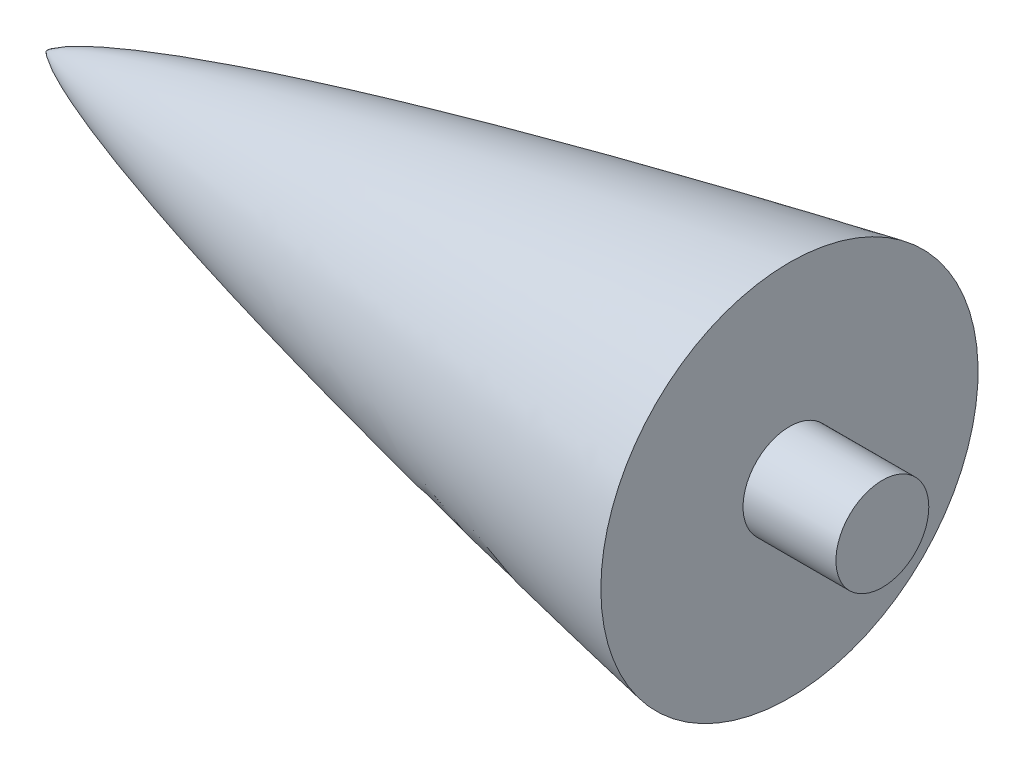
from build123d import *

# Parameters (mm, degrees)
SKETCH4_R           = 6.35
BOSS_EXTRUDE1_DEPTH = 12.7


with BuildPart() as part:
    # Sketch3 → Revolve1 (revolve)
    with BuildSketch(Plane.XY):
        with BuildLine():
            add(Edge.make_bspline(
                [(0, 0), (0.00238036, 0.007601136), (0.007984668, 0.02238567), (0.022840115, 0.050183387), (0.060232661, 0.101267557), (0.117712206, 0.166235145), (0.197260922, 0.242935889), (0.316636954, 0.345966559), (0.466313208, 0.461855796), (0.641104575, 0.585434487), (0.840927564, 0.716336462), (1.086304001, 0.86807874), (1.380514078, 1.039152539), (1.73039943, 1.230599419), (2.103920597, 1.423549594), (2.449515618, 1.594641657), (2.834258254, 1.779027289), (3.32523533, 2.006394535), (3.958237366, 2.287012777), (5.248383466, 2.831975888), (7.70022289, 3.78712851), (12.418398776, 5.434898892), (21.487866849, 8.204456936), (34.202358645, 11.566587315), (49.983706669, 15.304073444), (69.575752544, 19.539868175), (84.607400149, 22.552252216), (95.288419382, 24.602752796), (101.6, 25.78723001)],
                knots=[0, 0, 0, 0, 0, 2.0552e-05, 4.1103e-05, 8.2207e-05, 0.000164413, 0.00024662, 0.000328826, 0.000493239, 0.000657652, 0.000804573, 0.000951494, 0.001245335, 0.001544792, 0.001844249, 0.002047451, 0.002250653, 0.002657057, 0.003254789, 0.00385252, 0.005901677, 0.009515863, 0.016280764, 0.028569004, 0.040181404, 0.051793804, 0.068535654, 0.068535654, 0.068535654, 0.068535654, 0.068535654], degree=4))
            Line((0, 0), (101.6, 0))
            Line((101.6, 0), (101.6, 25.78723001))
        make_face()
    revolve(axis=Axis((183.101312307, 0, 0), (1, 0, 0)))

    # Sketch4 → Boss-Extrude1 (add)
    with BuildSketch(Plane(origin=(101.6, 0, 0), x_dir=(0, 0, -1), z_dir=(1, 0, 0))):
        Circle(SKETCH4_R)
    extrude(amount=BOSS_EXTRUDE1_DEPTH)


solid = part.part
